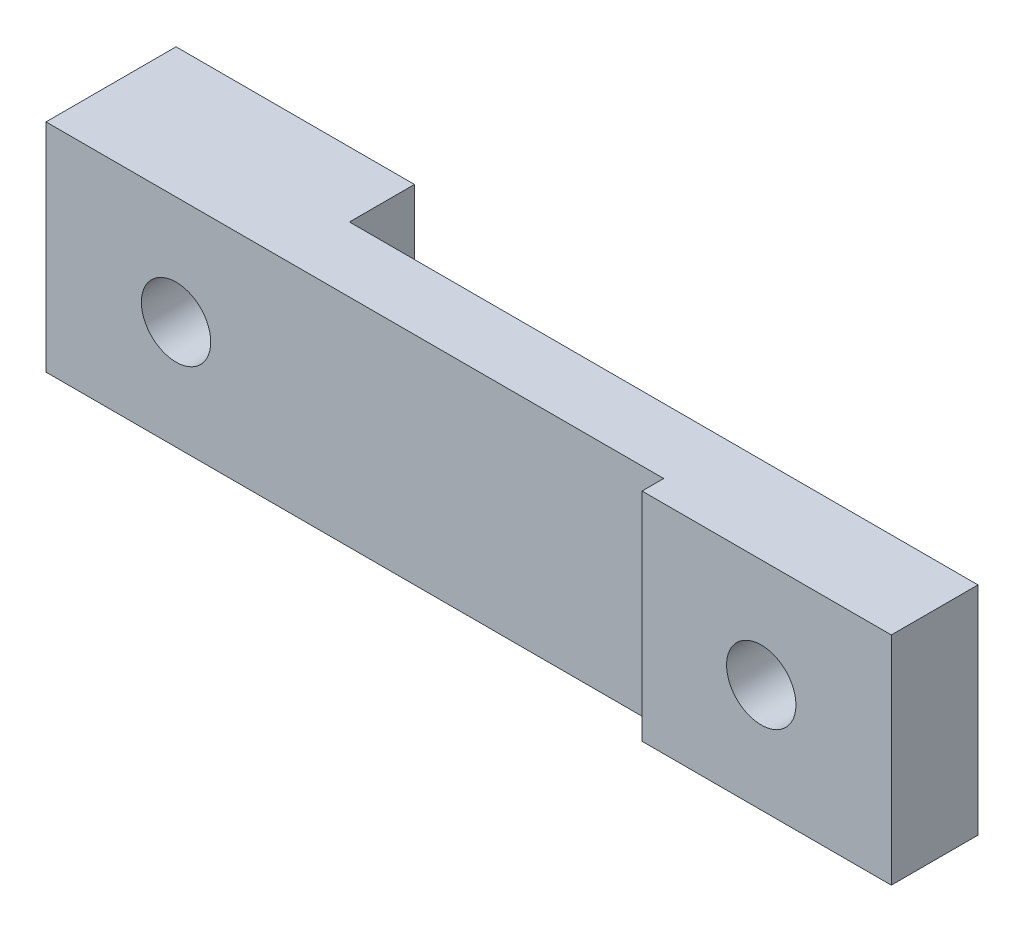
from build123d import *

# Parameters (mm, degrees)
SKETCH_1_W               = 35
SKETCH_1_H               = 10
EXTRUDE_1_DEPTH          = 3
SKETCH_2_W               = 9
SKETCH_2_H               = 10
EXTRUDE_2_DEPTH          = 1
SKETCH_3_R               = 1
EXTRUDE_3_DEPTH          = 8
SKETCH_4_W               = 6
SKETCH_4_H               = 10
EXTRUDE_4_DEPTH          = 3
SKETCH_5_R               = 1.5
CUT_EXTRUDE_1_DEPTH      = 6
SKETCH_6_W               = 6
SKETCH_6_H               = 10
EXTRUDE_5_DEPTH          = 5
SKETCH_7_R               = 1.6
CUT_EXTRUDE_2_DEPTH      = 8
CUT_EXTRUDE_2_DEPTH_BACK = 4
SKETCH_8_W               = 4
SKETCH_8_H               = 10
EXTRUDE_6_DEPTH          = 2.5
SKETCH_10_R              = 1.6
CUT_EXTRUDE_3_DEPTH      = 7
SKETCH_11_W              = 3
SKETCH_11_H              = 10
EXTRUDE_7_DEPTH          = 2.5
SKETCH_12_W              = 6
SKETCH_12_H              = 10
CUT_EXTRUDE_4_DEPTH      = 2.5


with BuildPart() as part:
    # 草圖1 → 填料-伸長1 (new body)
    with BuildSketch(Plane.XY):
        Rectangle(SKETCH_1_W, SKETCH_1_H)
    extrude(amount=EXTRUDE_1_DEPTH)

    # 草圖2 → 填料-伸長2 (add)
    with BuildSketch(Plane.XY.offset(3)):
        with Locations((13, 0)):
            Rectangle(SKETCH_2_W, SKETCH_2_H)
    extrude(amount=EXTRUDE_2_DEPTH)

    # 草圖3 → 填料-伸長3 (add)
    with BuildSketch(Plane.XY.offset(4)):
        with Locations((14, 0)):
            Circle(SKETCH_3_R)
    extrude(amount=EXTRUDE_3_DEPTH)

    # 草圖4 → 填料-伸長4 (add)
    with BuildSketch(Plane(origin=(0, 0, 0), x_dir=(-1, 0, 0), z_dir=(0, 0, -1))):
        with Locations((14.5, 0)):
            Rectangle(SKETCH_4_W, SKETCH_4_H)
    extrude(amount=EXTRUDE_4_DEPTH)

    # 草圖5 → 除料-伸長1 (cut)
    with BuildSketch(Plane(origin=(0, 0, -3), x_dir=(-1, 0, 0), z_dir=(0, 0, -1))):
        with Locations((14, 0)):
            Circle(SKETCH_5_R)
    extrude(amount=-CUT_EXTRUDE_1_DEPTH, mode=Mode.SUBTRACT)

    # 草圖6 → 填料-伸長5 (add)
    with BuildSketch(Plane.ZY.offset(17.5)):
        Rectangle(SKETCH_6_W, SKETCH_6_H)
    extrude(amount=EXTRUDE_5_DEPTH)

    # 草圖7 → 除料-伸長2 (cut, two sides)
    with BuildSketch(Plane.XY.offset(4)) as cut_extrude_2_sk:
        with Locations((14, 0)):
            Circle(SKETCH_7_R)
    extrude(amount=CUT_EXTRUDE_2_DEPTH, mode=Mode.SUBTRACT)
    extrude(cut_extrude_2_sk.sketch, amount=-CUT_EXTRUDE_2_DEPTH_BACK, mode=Mode.SUBTRACT)

    # 草圖8 → 填料-伸長6 (add)
    with BuildSketch(Plane(origin=(17.5, 0, 0), x_dir=(0, 0, -1), z_dir=(1, 0, 0))):
        with Locations((-2, 0)):
            Rectangle(SKETCH_8_W, SKETCH_8_H)
    extrude(amount=EXTRUDE_6_DEPTH)

    # 草圖10 → 除料-伸長3 (cut)
    with BuildSketch(Plane(origin=(0, 0, -3), x_dir=(-1, 0, 0), z_dir=(0, 0, -1))):
        with Locations((14, 0)):
            Circle(SKETCH_10_R)
    extrude(amount=-CUT_EXTRUDE_3_DEPTH, mode=Mode.SUBTRACT)

    # 草圖11 → 填料-伸長7 (add)
    with BuildSketch(Plane(origin=(-11.5, 0, 0), x_dir=(0, 0, -1), z_dir=(1, 0, 0))):
        with Locations((1.5, 0)):
            Rectangle(SKETCH_11_W, SKETCH_11_H)
    extrude(amount=EXTRUDE_7_DEPTH)

    # 草圖12 → 除料-伸長4 (cut)
    with BuildSketch(Plane.ZY.offset(22.5)):
        Rectangle(SKETCH_12_W, SKETCH_12_H)
    extrude(amount=-CUT_EXTRUDE_4_DEPTH, mode=Mode.SUBTRACT)


solid = part.part
